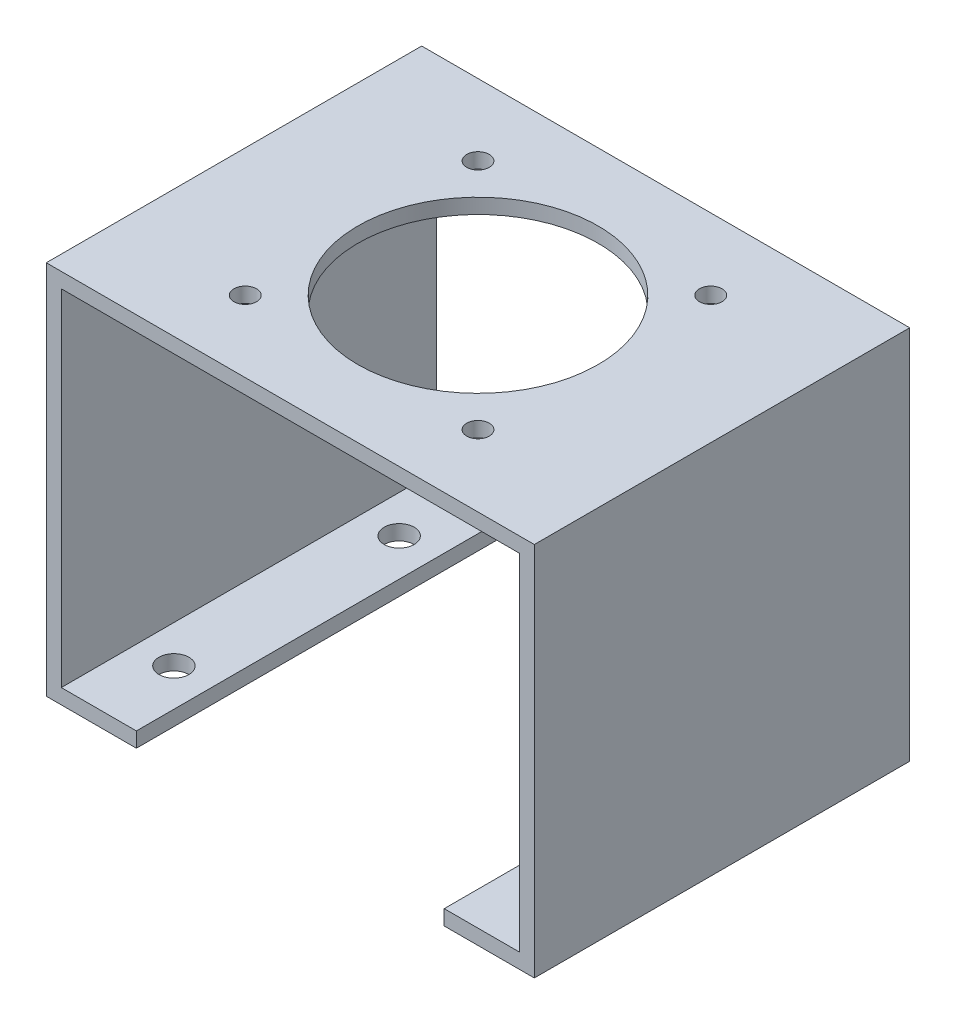
from build123d import *

# Parameters (mm, degrees)
ESBO_O1_W                = 65
ESBO_O1_H                = 50
RESSALTO_EXTRUS_O1_DEPTH = 2
ESBO_O2_W                = 50
ESBO_O2_H                = 50
RESSALTO_EXTRUS_O2_DEPTH = 2
ESBO_O3_W                = 50
ESBO_O3_H                = 2
RESSALTO_EXTRUS_O3_DEPTH = 10
ESBO_O4_R                = 1.5
CORTE_EXTRUS_O1_DEPTH    = 51
ESBO_O5_R                = 16
ESBO_O5_R_2              = 2.5
CORTE_EXTRUS_O2_DEPTH    = 10
ESBO_O6_R                = 2
CORTE_EXTRUS_O3_DEPTH    = 10


with BuildPart() as part:
    # Esboço1 → Ressalto-extrusão1 (new body)
    with BuildSketch(Plane(origin=(0, 0, 0), x_dir=(1, 0, 0), z_dir=(0, 1, 0))):
        Rectangle(ESBO_O1_W, ESBO_O1_H)
    extrude(amount=-RESSALTO_EXTRUS_O1_DEPTH)

    # Esboço2 → Ressalto-extrusão2 (add)
    with BuildSketch(Plane.ZY.offset(32.5)):
        with Locations((0, -25)):
            Rectangle(ESBO_O2_W, ESBO_O2_H)
    ressalto_extrus_o2 = extrude(amount=-RESSALTO_EXTRUS_O2_DEPTH)

    # Esboço3 → Ressalto-extrusão3 (add)
    with BuildSketch(Plane(origin=(-30.5, 0, 0), x_dir=(0, 0, -1), z_dir=(1, 0, 0))):
        with Locations((0, -49)):
            Rectangle(ESBO_O3_W, ESBO_O3_H)
    ressalto_extrus_o3 = extrude(amount=RESSALTO_EXTRUS_O3_DEPTH)

    # Espelhar1: Ressalto-extrusão2, Ressalto-extrusão3 across plane
    add(ressalto_extrus_o2.mirror(Plane(origin=(0, 0, 0), x_dir=(0, 0, 1), z_dir=(1, 0, 0))))
    add(ressalto_extrus_o3.mirror(Plane(origin=(0, 0, 0), x_dir=(0, 0, 1), z_dir=(1, 0, 0))))

    # Esboço4 → Corte-extrusão1 (cut, through all)
    with BuildSketch(Plane(origin=(0, 0, 0), x_dir=(1, 0, 0), z_dir=(0, 1, 0))):
        with Locations((-15.5, 15.5)):
            Circle(ESBO_O4_R)
        with Locations((-15.5, -15.5)):
            Circle(ESBO_O4_R)
        with Locations((15.5, -15.5)):
            Circle(ESBO_O4_R)
        with Locations((15.5, 15.5)):
            Circle(ESBO_O4_R)
    extrude(amount=-CORTE_EXTRUS_O1_DEPTH, mode=Mode.SUBTRACT)

    # Esboço5 → Corte-extrusão2 (cut)
    with BuildSketch(Plane(origin=(0, 0, 0), x_dir=(1, 0, 0), z_dir=(0, 1, 0))):
        Circle(ESBO_O5_R)
        Circle(ESBO_O5_R_2, mode=Mode.SUBTRACT)
        Circle(ESBO_O5_R_2)
    extrude(amount=-CORTE_EXTRUS_O2_DEPTH, mode=Mode.SUBTRACT)

    # Esboço6 → Corte-extrusão3 (cut)
    with BuildSketch(Plane(origin=(0, -48, 0), x_dir=(1, 0, 0), z_dir=(0, 1, 0))):
        with Locations((-25.5, -15)):
            Circle(ESBO_O6_R)
        with Locations((25.5, -15)):
            Circle(ESBO_O6_R)
        with Locations((25.5, 15)):
            Circle(ESBO_O6_R)
        with Locations((-25.5, 15)):
            Circle(ESBO_O6_R)
    extrude(amount=-CORTE_EXTRUS_O3_DEPTH, mode=Mode.SUBTRACT)


solid = part.part
